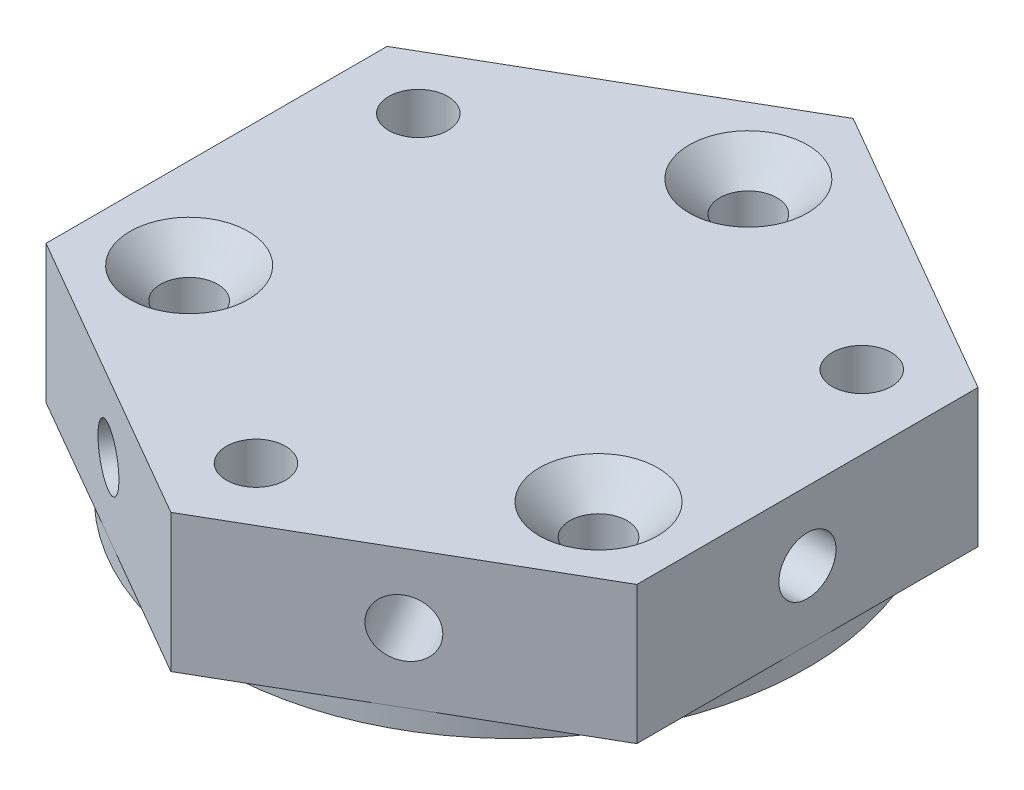
from build123d import *

# Parameters (mm, degrees)
SKETCH_1_R          = 15
SKETCH_1_R_2        = 1.45
SKETCH_1_R_3        = 1.5
EXTRUDE_1_DEPTH     = 8
SKETCH_2_R          = 1.45
SKETCH_2_R_2        = 1.5
EXTRUDE_2_DEPTH     = 7
SKETCH_3_R          = 1.45
CUT_EXTRUDE_1_DEPTH = 8
SKETCH_4_R          = 1.45
CUT_EXTRUDE_2_DEPTH = 8
SKETCH_5_R          = 1.45
CUT_EXTRUDE_3_DEPTH = 8
SKETCH_6_R          = 1.45
CUT_EXTRUDE_4_DEPTH = 8
SKETCH_7_R          = 1.45
CUT_EXTRUDE_5_DEPTH = 8
SKETCH_8_R          = 1.5
CUT_EXTRUDE_6_DEPTH = 8
CHAMFER_1_SIZE      = 1.55


with BuildPart() as part:
    # 草图1 → 凸台-拉伸1 (new body)
    with BuildSketch(Plane(origin=(0, 0, 0), x_dir=(1, 0, 0), z_dir=(0, 1, 0))):
        Circle(SKETCH_1_R)
        with Locations((0, 12)):
            Circle(SKETCH_1_R_2, mode=Mode.SUBTRACT)
        with Locations((-10.392304845, -6)):
            Circle(SKETCH_1_R_2, mode=Mode.SUBTRACT)
        with Locations((10.392304845, -6)):
            Circle(SKETCH_1_R_2, mode=Mode.SUBTRACT)
        with Locations((-11.258330249, 6.5)):
            Circle(SKETCH_1_R_3, mode=Mode.SUBTRACT)
        with Locations((0, -13)):
            Circle(SKETCH_1_R_3, mode=Mode.SUBTRACT)
        with Locations((11.258330249, 6.5)):
            Circle(SKETCH_1_R_3, mode=Mode.SUBTRACT)
    extrude(amount=EXTRUDE_1_DEPTH)

    # 草图2 → 凸台-拉伸2 (add)
    with BuildSketch(Plane(origin=(0, 8, 0), x_dir=(1, 0, 0), z_dir=(0, 1, 0))):
        Polygon((0, 17.320508076), (-15, 8.660254038), (-15, -8.660254038), (0, -17.320508076), (15, -8.660254038), (15, 8.660254038), align=None)
        with Locations((0, 12)):
            Circle(SKETCH_2_R, mode=Mode.SUBTRACT)
        with Locations((-11.258330249, 6.5)):
            Circle(SKETCH_2_R_2, mode=Mode.SUBTRACT)
        with Locations((11.258330249, 6.5)):
            Circle(SKETCH_2_R_2, mode=Mode.SUBTRACT)
        with Locations((-10.392304845, -6)):
            Circle(SKETCH_2_R, mode=Mode.SUBTRACT)
        with Locations((0, -13)):
            Circle(SKETCH_2_R_2, mode=Mode.SUBTRACT)
        with Locations((10.392304845, -6)):
            Circle(SKETCH_2_R, mode=Mode.SUBTRACT)
    extrude(amount=-EXTRUDE_2_DEPTH)

    # 草图3 → 切除-拉伸1 (cut)
    with BuildSketch(Plane(origin=(7.5, 0, 12.990381057), x_dir=(0.866025404, 0, -0.5), z_dir=(0.5, 0, 0.866025404))):
        with Locations((0, 4.5)):
            Circle(SKETCH_3_R)
    extrude(amount=-CUT_EXTRUDE_1_DEPTH, mode=Mode.SUBTRACT)

    # 草图4 → 切除-拉伸2 (cut)
    with BuildSketch(Plane(origin=(-7.5, 0, 12.990381057), x_dir=(0.866025404, 0, 0.5), z_dir=(-0.5, 0, 0.866025404))):
        with Locations((0, 4.5)):
            Circle(SKETCH_4_R)
    extrude(amount=-CUT_EXTRUDE_2_DEPTH, mode=Mode.SUBTRACT)

    # 草图5 → 切除-拉伸3 (cut)
    with BuildSketch(Plane.ZY.offset(15)):
        with Locations((0, 4.5)):
            Circle(SKETCH_5_R)
    extrude(amount=-CUT_EXTRUDE_3_DEPTH, mode=Mode.SUBTRACT)

    # 草图6 → 切除-拉伸4 (cut)
    with BuildSketch(Plane(origin=(15, 0, 0), x_dir=(0, 0, -1), z_dir=(1, 0, 0))):
        with Locations((0, 4.5)):
            Circle(SKETCH_6_R)
    extrude(amount=-CUT_EXTRUDE_4_DEPTH, mode=Mode.SUBTRACT)

    # 草图7 → 切除-拉伸5 (cut)
    with BuildSketch(Plane(origin=(7.5, 0, -12.990381057), x_dir=(-0.866025404, 0, -0.5), z_dir=(0.5, 0, -0.866025404))):
        with Locations((0, 4.5)):
            Circle(SKETCH_7_R)
    extrude(amount=-CUT_EXTRUDE_5_DEPTH, mode=Mode.SUBTRACT)

    # 草图8 → 切除-拉伸6 (cut)
    with BuildSketch(Plane(origin=(-7.5, 0, -12.990381057), x_dir=(-0.866025404, 0, 0.5), z_dir=(-0.5, 0, -0.866025404))):
        with Locations((0, 4.5)):
            Circle(SKETCH_8_R)
    extrude(amount=-CUT_EXTRUDE_6_DEPTH, mode=Mode.SUBTRACT)

    # 倒角1
    chamfer_1_edges = [part.edges().sort_by_distance(p)[0] for p in [
        (8.942304845, 8, 6),
        (-1.45, 8, -12),
        (-11.842304845, 8, 6),
    ]]
    chamfer(chamfer_1_edges, length=CHAMFER_1_SIZE)


solid = part.part
